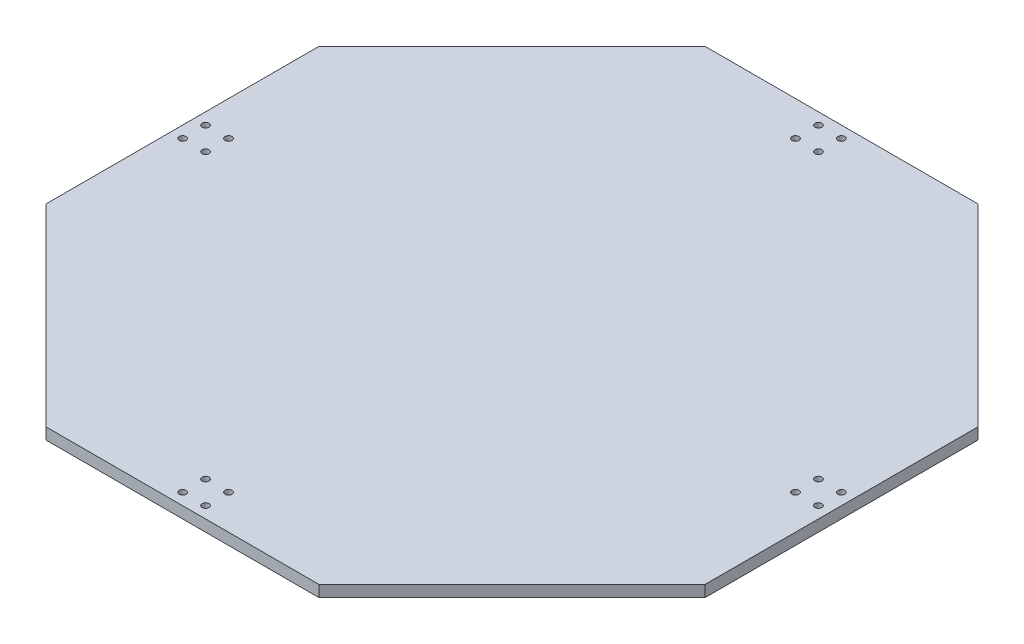
from build123d import *

# Parameters (mm, degrees)
SKETCH_1_R      = 1.5
EXTRUDE_1_DEPTH = 5


with BuildPart() as part:
    # 스케치1 → 보스-돌출1 (new body)
    with BuildSketch(Plane(origin=(0, 0, 0), x_dir=(1, 0, 0), z_dir=(0, 1, 0))):
        Polygon((59.481067557, -143.6), (143.6, -59.481067557), (143.6, 59.481067557), (59.481067557, 143.6), (-59.481067557, 143.6), (-143.6, 59.481067557), (-143.6, -59.481067557), (-59.481067557, -143.6), align=None)
        with Locations((-5, 138.54)):
            Circle(SKETCH_1_R, mode=Mode.SUBTRACT)
        with Locations((-5, 128.54)):
            Circle(SKETCH_1_R, mode=Mode.SUBTRACT)
        with Locations((5, 128.54)):
            Circle(SKETCH_1_R, mode=Mode.SUBTRACT)
        with Locations((5, 138.54)):
            Circle(SKETCH_1_R, mode=Mode.SUBTRACT)
        with Locations((138.54, 5)):
            Circle(SKETCH_1_R, mode=Mode.SUBTRACT)
        with Locations((128.54, 5)):
            Circle(SKETCH_1_R, mode=Mode.SUBTRACT)
        with Locations((128.54, -5)):
            Circle(SKETCH_1_R, mode=Mode.SUBTRACT)
        with Locations((138.54, -5)):
            Circle(SKETCH_1_R, mode=Mode.SUBTRACT)
        with Locations((5, -138.54)):
            Circle(SKETCH_1_R, mode=Mode.SUBTRACT)
        with Locations((5, -128.54)):
            Circle(SKETCH_1_R, mode=Mode.SUBTRACT)
        with Locations((-5, -128.54)):
            Circle(SKETCH_1_R, mode=Mode.SUBTRACT)
        with Locations((-5, -138.54)):
            Circle(SKETCH_1_R, mode=Mode.SUBTRACT)
        with Locations((-138.54, -5)):
            Circle(SKETCH_1_R, mode=Mode.SUBTRACT)
        with Locations((-128.54, -5)):
            Circle(SKETCH_1_R, mode=Mode.SUBTRACT)
        with Locations((-128.54, 5)):
            Circle(SKETCH_1_R, mode=Mode.SUBTRACT)
        with Locations((-138.54, 5)):
            Circle(SKETCH_1_R, mode=Mode.SUBTRACT)
    extrude(amount=EXTRUDE_1_DEPTH)


solid = part.part
